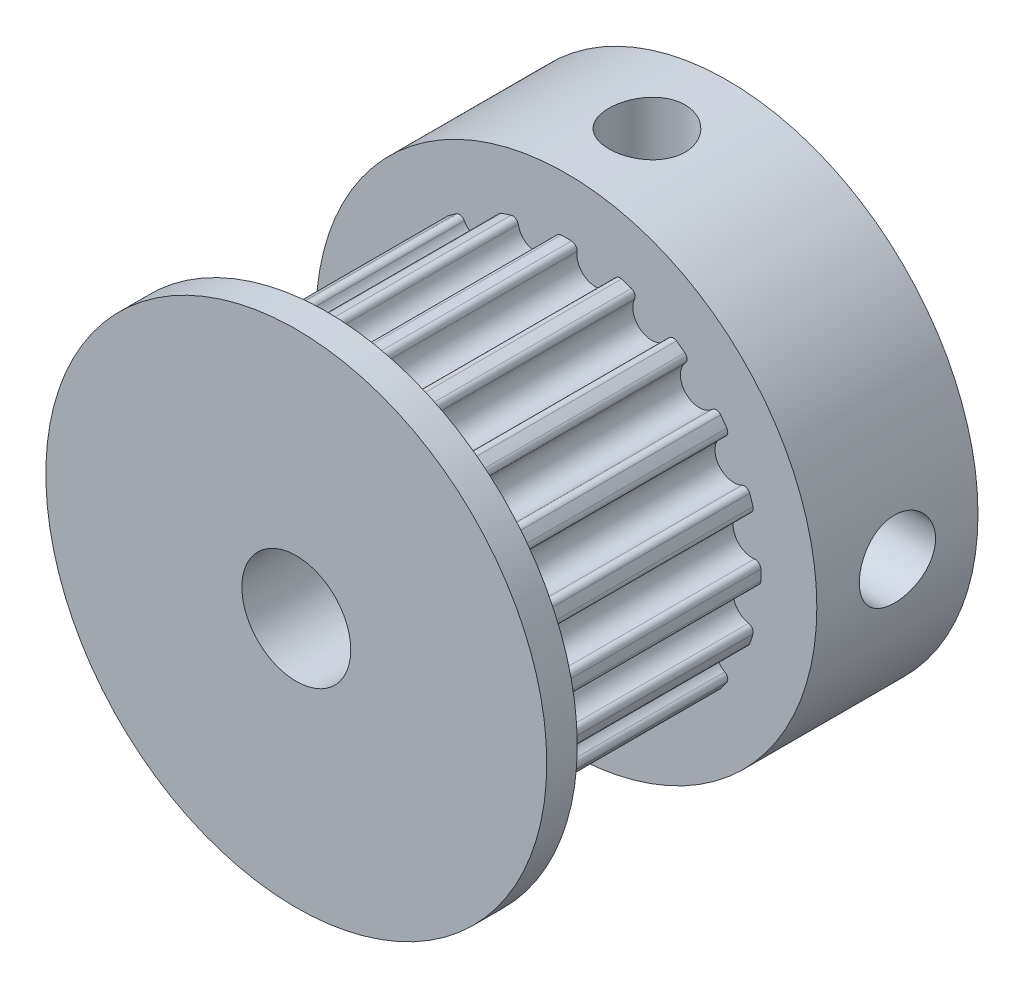
from build123d import *

# Parameters (mm, degrees)
BOSS_EXTRUDE1_DEPTH       = 11
FILLET2_R                 = 0.26
CIRPATTERN12_COUNT        = 20
FILLET2_OF_CIRPATTERN12_R = 0.26
SKETCH3_R                 = 2.5
SKETCH3_R_2               = 11.5
BOSS_EXTRUDE2_DEPTH       = 7.4
BOSS_EXTRUDE3_START       = 11
SKETCH3_3_R               = 2.5
SKETCH3_3_R_2             = 11.5
BOSS_EXTRUDE3_DEPTH       = 1.4
SKETCH3_4_R               = 2.5
CUT_EXTRUDE1_DEPTH        = 13.4
CUT_EXTRUDE1_DEPTH_BACK   = 8.4
CUT_EXTRUDE2_START        = -9.714643
SKETCH4_R                 = 1.75
CUT_EXTRUDE2_DEPTH        = 9.714643
CUT_EXTRUDE3_START        = -9.714643
SKETCH5_R                 = 1.75
CUT_EXTRUDE3_DEPTH        = 9.714643


with BuildPart() as part:
    # Sketch2 → Boss-Extrude1 (new body)
    with BuildSketch(Plane(origin=(0, 0, 0), x_dir=(0, 1, 0), z_dir=(0, 0, 1))):
        with BuildLine():
            ThreePointArc((2.211181489, 8.656346337), (2.487291524, 8.581085966), (2.760849478, 8.497020986))
            Line((2.760849478, 8.497020986), (0, 0))
            Line((0, 0), (0, 8.934296586))
            ThreePointArc((0, 8.934296586), (0.286146582, 8.929713076), (0.571999564, 8.915967249))
            ThreePointArc((0.571999564, 8.915967249), (1.214603583, 7.66870521), (2.211181489, 8.656346337))
        make_face()
    boss_extrude1 = extrude(amount=BOSS_EXTRUDE1_DEPTH)

    # Fillet2
    fillet2_edges = [part.edges().sort_by_distance(p)[0] for p in [
        (-8.915967249, 0.571999564, 5.5),
        (-8.656346337, 2.211181489, 5.5),
    ]]
    fillet(fillet2_edges, radius=FILLET2_R)

    # CirPattern12: Boss-Extrude1 ×20 about axis
    cirpattern12_axis = Axis((0, 0, 0), (0, 0, 1))
    for i in range(1, CIRPATTERN12_COUNT):
        add(boss_extrude1.rotate(cirpattern12_axis, i * 360 / CIRPATTERN12_COUNT))

    # Fillet2 of CirPattern12
    fillet2_of_cirpattern12_edges = [part.edges().sort_by_distance(p)[0] for p in [
        (-8.656346337, -2.211181489, 5.5),
        (-8.915967249, -0.571999564, 5.5),
        (-7.549381933, -4.777916691, 5.5),
        (-8.302831165, -3.299189314, 5.5),
        (-5.703431427, -6.876956117, 5.5),
        (-6.876956117, -5.703431427, 5.5),
        (-3.299189314, -8.302831165, 5.5),
        (-4.777916691, -7.549381933, 5.5),
        (-0.571999564, -8.915967249, 5.5),
        (-2.211181489, -8.656346337, 5.5),
        (2.211181489, -8.656346337, 5.5),
        (0.571999564, -8.915967249, 5.5),
        (4.777916691, -7.549381933, 5.5),
        (3.299189314, -8.302831165, 5.5),
        (6.876956117, -5.703431427, 5.5),
        (5.703431427, -6.876956117, 5.5),
        (8.302831165, -3.299189314, 5.5),
        (7.549381933, -4.777916691, 5.5),
        (8.915967249, -0.571999564, 5.5),
        (8.656346337, -2.211181489, 5.5),
        (8.656346337, 2.211181489, 5.5),
        (8.915967249, 0.571999564, 5.5),
        (7.549381933, 4.777916691, 5.5),
        (8.302831165, 3.299189314, 5.5),
        (5.703431427, 6.876956117, 5.5),
        (6.876956117, 5.703431427, 5.5),
        (3.299189314, 8.302831165, 5.5),
        (4.777916691, 7.549381933, 5.5),
        (0.571999564, 8.915967249, 5.5),
        (2.211181489, 8.656346337, 5.5),
        (-2.211181489, 8.656346337, 5.5),
        (-0.571999564, 8.915967249, 5.5),
        (-4.777916691, 7.549381933, 5.5),
        (-3.299189314, 8.302831165, 5.5),
        (-6.876956117, 5.703431427, 5.5),
        (-5.703431427, 6.876956117, 5.5),
        (-8.302831165, 3.299189314, 5.5),
        (-7.549381933, 4.777916691, 5.5),
    ]]
    fillet(fillet2_of_cirpattern12_edges, radius=FILLET2_OF_CIRPATTERN12_R)

    # Sketch3 → Boss-Extrude2 (add)
    with BuildSketch(Plane(origin=(0, 0, 0), x_dir=(0, 1, 0), z_dir=(0, 0, 1))):
        Circle(SKETCH3_R)
        Circle(SKETCH3_R_2)
        Circle(SKETCH3_R, mode=Mode.SUBTRACT)
    extrude(amount=-BOSS_EXTRUDE2_DEPTH)

    # Sketch3_3 → Boss-Extrude3 (add)
    with BuildSketch(Plane(origin=(0, 0, 0), x_dir=(0, 1, 0), z_dir=(0, 0, 1)).offset(BOSS_EXTRUDE3_START)):
        Circle(SKETCH3_3_R)
        Circle(SKETCH3_3_R_2)
        Circle(SKETCH3_3_R, mode=Mode.SUBTRACT)
    extrude(amount=BOSS_EXTRUDE3_DEPTH)

    # Sketch3_4 → Cut-Extrude1 (cut, two sides)
    with BuildSketch(Plane(origin=(0, 0, 0), x_dir=(0, 1, 0), z_dir=(0, 0, 1))) as cut_extrude1_sk:
        Circle(SKETCH3_4_R)
    extrude(amount=CUT_EXTRUDE1_DEPTH, mode=Mode.SUBTRACT)
    extrude(cut_extrude1_sk.sketch, amount=-CUT_EXTRUDE1_DEPTH_BACK, mode=Mode.SUBTRACT)

    # Sketch4 → Cut-Extrude2 (cut)
    with BuildSketch(Plane(origin=(11.5, 0, 0), x_dir=(0, 0, -1), z_dir=(1, 0, 0)).offset(CUT_EXTRUDE2_START)):
        with Locations((3.7, 0)):
            Circle(SKETCH4_R)
    extrude(amount=CUT_EXTRUDE2_DEPTH, mode=Mode.SUBTRACT)

    # Sketch5 → Cut-Extrude3 (cut)
    with BuildSketch(Plane.ZX.offset(11.5).offset(CUT_EXTRUDE3_START)):
        with Locations((-3.7, 0)):
            Circle(SKETCH5_R)
    extrude(amount=CUT_EXTRUDE3_DEPTH, mode=Mode.SUBTRACT)


solid = part.part
